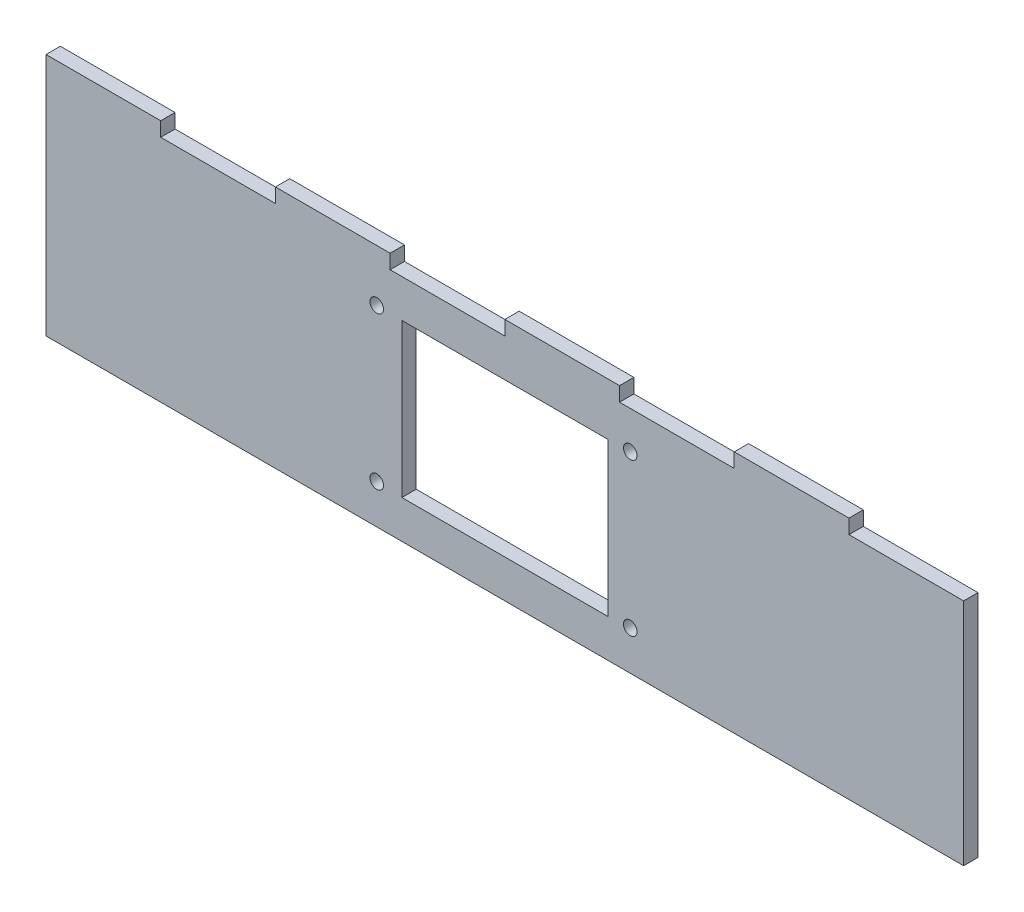
from build123d import *

# Parameters (mm, degrees)
SKETCH1_W           = 203.2
SKETCH1_H           = 50.8
BOSS_EXTRUDE1_DEPTH = 3.175
SKETCH2_R           = 1.5
SKETCH2_W           = 45.6
SKETCH2_H           = 33.96
CUT_EXTRUDE1_DEPTH  = 3.175
SKETCH3_W           = 25.4
SKETCH3_H           = 3.175
BOSS_EXTRUDE2_DEPTH = 3.175


with BuildPart() as part:
    # Sketch1 → Boss-Extrude1 (new body)
    with BuildSketch(Plane.XY):
        Rectangle(SKETCH1_W, SKETCH1_H)
    extrude(amount=BOSS_EXTRUDE1_DEPTH)

    # Sketch2 → Cut-Extrude1 (cut)
    with BuildSketch(Plane.XY.offset(3.175)):
        with Locations((27.769072573, 17.082783056)):
            Circle(SKETCH2_R)
        with Locations((-28.364927427, 17.082783056)):
            Circle(SKETCH2_R)
        with Locations((-28.364927427, -16.699216944)):
            Circle(SKETCH2_R)
        with Locations((27.769072573, -16.699216944)):
            Circle(SKETCH2_R)
        Rectangle(SKETCH2_W, SKETCH2_H)
    extrude(amount=-CUT_EXTRUDE1_DEPTH, mode=Mode.SUBTRACT)

    # Sketch3 → Boss-Extrude2 (add)
    with BuildSketch(Plane.XY.offset(3.175)):
        with Locations((-38.1, 26.9875)):
            Rectangle(SKETCH3_W, SKETCH3_H)
        with Locations((-88.9, 26.9875)):
            Rectangle(SKETCH3_W, SKETCH3_H)
        with Locations((12.7, 26.9875)):
            Rectangle(SKETCH3_W, SKETCH3_H)
        with Locations((63.5, 26.9875)):
            Rectangle(SKETCH3_W, SKETCH3_H)
    extrude(amount=-BOSS_EXTRUDE2_DEPTH)


solid = part.part
